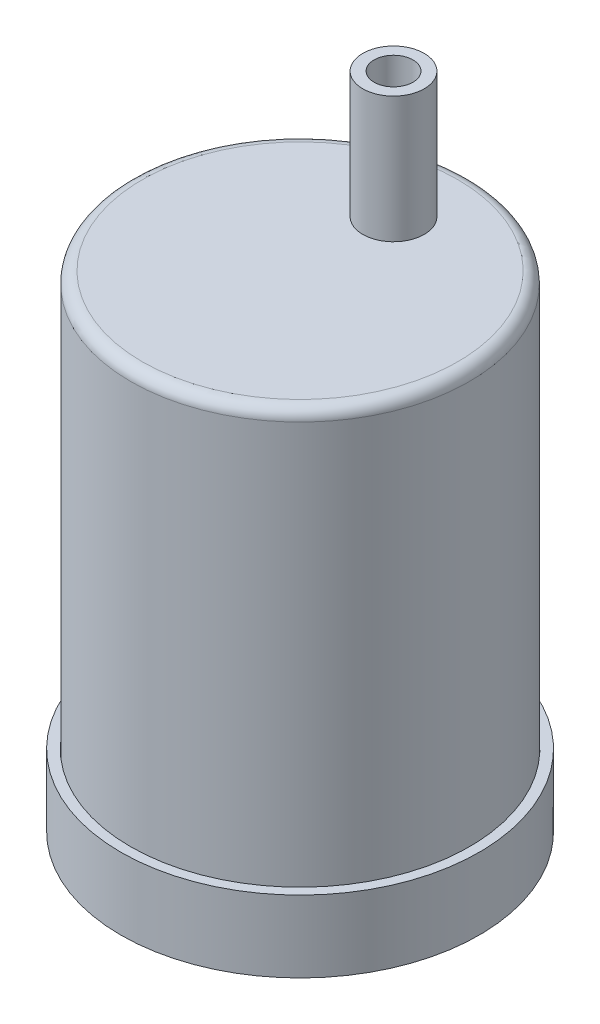
from build123d import *

# Parameters (mm, degrees)
SKETCH1_R            = 19.85
SKETCH1_R_2          = 18.78
BOSS_EXTRUDE3_DEPTH  = 7.95
SKETCH2_R            = 18.78
BOSS_EXTRUDE5_DEPTH  = 1.5
SKETCH4_R            = 12.5
BOSS_EXTRUDE6_DEPTH  = 16.31
SKETCH5_R            = 2.15
SKETCH5_W            = 4.3
SKETCH5_H            = 2.15
CUT_EXTRUDE2_DEPTH   = 16.31
SKETCH6_R            = 11.597360911
CUT_EXTRUDE3_DEPTH   = 14.809999892
SKETCH12_R           = 3.4
SKETCH12_W           = 6.8
SKETCH12_H           = 3.4
BOSS_EXTRUDE8_DEPTH  = 24.969999892
SKETCH5_6_R          = 2.15
SKETCH5_6_W          = 4.3
SKETCH5_6_H          = 2.15
CUT_EXTRUDE5_DEPTH   = 24.969999892
CUT_EXTRUDE6_START   = -14.81
SKETCH14_R           = 15.219310499
SKETCH14_R_2         = 12.5
CUT_EXTRUDE6_DEPTH   = 14.81
SKETCH17_W           = 6.8
SKETCH17_H           = 2.662223843
CUT_EXTRUDE7_DEPTH   = 16.587999892
SKETCH18_R           = 3.4
SKETCH18_R_2         = 2.15
BOSS_EXTRUDE10_DEPTH = 14
SKETCH19_R           = 5.618160511
SKETCH19_R_2         = 3.4
CUT_EXTRUDE8_DEPTH   = 14
SKETCH20_R           = 18.7419
SKETCH20_R_2         = 17.5419
BOSS_EXTRUDE11_DEPTH = 50.8
SKETCH21_R           = 18.7419
BOSS_EXTRUDE12_DEPTH = 1.5
SKETCH22_R           = 3.4
SKETCH22_R_2         = 2.15
BOSS_EXTRUDE13_DEPTH = 13.97
SKETCH23_R           = 2.15
CUT_EXTRUDE9_DEPTH   = 30.456
FILLET1_R            = 1.27
FILLET2_R            = 1.27


with BuildPart() as part:
    # Sketch1 → Boss-Extrude3 (new body)
    with BuildSketch(Plane(origin=(0, 0, 0), x_dir=(1, 0, 0), z_dir=(0, 1, 0))):
        Circle(SKETCH1_R)
        Circle(SKETCH1_R_2, mode=Mode.SUBTRACT)
    extrude(amount=BOSS_EXTRUDE3_DEPTH)

    # Sketch2 → Boss-Extrude5 (add)
    with BuildSketch(Plane.XZ):
        Circle(SKETCH2_R)
    extrude(amount=-BOSS_EXTRUDE5_DEPTH)


with BuildPart() as body_2:
    # Sketch4 → Boss-Extrude6 (new body)
    with BuildSketch(Plane.XZ):
        Circle(SKETCH4_R)
    extrude(amount=-BOSS_EXTRUDE6_DEPTH)


with BuildPart() as cut_extrude2_tool:
    # Sketch5 → Cut-Extrude2 (new body)
    with BuildSketch(Plane(origin=(0, 16.31, 0), x_dir=(1, 0, 0), z_dir=(0, 1, 0))):
        with Locations((0, 10.35)):
            Circle(SKETCH5_R)
        with Locations((0, 11.425)):
            Rectangle(SKETCH5_W, SKETCH5_H)
    extrude(amount=-CUT_EXTRUDE2_DEPTH)


with BuildPart() as part_1:
    add(part.part)

    # Cut-Extrude2: cut by cut_extrude2_tool
    add(cut_extrude2_tool.part, mode=Mode.SUBTRACT)


with BuildPart() as body_2_1:
    add(body_2.part)

    # Cut-Extrude2: cut by cut_extrude2_tool
    add(cut_extrude2_tool.part, mode=Mode.SUBTRACT)


with BuildPart() as cut_extrude3_tool:
    # Sketch6 → Cut-Extrude3 (new body)
    with BuildSketch(Plane.XZ):
        Circle(SKETCH6_R)
    extrude(amount=-CUT_EXTRUDE3_DEPTH)


with BuildPart() as part_2:
    add(part_1.part)

    # Cut-Extrude3: cut by cut_extrude3_tool
    add(cut_extrude3_tool.part, mode=Mode.SUBTRACT)



with BuildPart() as body_2_2:
    add(body_2_1.part)

    # Cut-Extrude3: cut by cut_extrude3_tool
    add(cut_extrude3_tool.part, mode=Mode.SUBTRACT)


with BuildPart() as part_3:
    add(part_2.part)

    add(body_2_2.part)  # Boss-Extrude8 merges body 2
    # Sketch12 → Boss-Extrude8 (add)
    with BuildSketch(Plane(origin=(0, 16.31, 0), x_dir=(1, 0, 0), z_dir=(0, 1, 0))):
        with Locations((0, 10.35)):
            Circle(SKETCH12_R)
        with Locations((0, 12.05)):
            Rectangle(SKETCH12_W, SKETCH12_H)
    extrude(amount=-BOSS_EXTRUDE8_DEPTH)

    # Sketch5_6 → Cut-Extrude5 (cut)
    with BuildSketch(Plane(origin=(0, 16.31, 0), x_dir=(1, 0, 0), z_dir=(0, 1, 0))):
        with Locations((0, 10.35)):
            Circle(SKETCH5_6_R)
        with Locations((0, 11.425)):
            Rectangle(SKETCH5_6_W, SKETCH5_6_H)
    extrude(amount=-CUT_EXTRUDE5_DEPTH, mode=Mode.SUBTRACT)

    # Sketch14 → Cut-Extrude6 (cut)
    with BuildSketch(Plane(origin=(0, 16.31, 0), x_dir=(1, 0, 0), z_dir=(0, 1, 0)).offset(CUT_EXTRUDE6_START)):
        Circle(SKETCH14_R)
        Circle(SKETCH14_R_2, mode=Mode.SUBTRACT)
    extrude(amount=CUT_EXTRUDE6_DEPTH, mode=Mode.SUBTRACT)

    # Sketch17 → Cut-Extrude7 (cut)
    with BuildSketch(Plane.XZ):
        with Locations((0, -12.418888079)):
            Rectangle(SKETCH17_W, SKETCH17_H)
    extrude(amount=CUT_EXTRUDE7_DEPTH, mode=Mode.SUBTRACT)

    # Sketch18 → Boss-Extrude10 (add)
    with BuildSketch(Plane.XZ):
        with Locations((0, -10.35)):
            Circle(SKETCH18_R)
        with Locations((0, -10.35)):
            Circle(SKETCH18_R_2, mode=Mode.SUBTRACT)
    extrude(amount=BOSS_EXTRUDE10_DEPTH)

    # Sketch19 → Cut-Extrude8 (cut)
    with BuildSketch(Plane.XZ):
        with Locations((0, -10.35)):
            Circle(SKETCH19_R)
        with Locations((0, -10.35)):
            Circle(SKETCH19_R_2, mode=Mode.SUBTRACT)
    extrude(amount=CUT_EXTRUDE8_DEPTH, mode=Mode.SUBTRACT)


with BuildPart() as body_2_2_1:
    # Sketch20 → Boss-Extrude11 (new body)
    with BuildSketch(Plane(origin=(0, 1.5, 0), x_dir=(1, 0, 0), z_dir=(0, 1, 0))):
        Circle(SKETCH20_R)
        Circle(SKETCH20_R_2, mode=Mode.SUBTRACT)
    extrude(amount=BOSS_EXTRUDE11_DEPTH)

    # Sketch21 → Boss-Extrude12 (add)
    with BuildSketch(Plane(origin=(0, 52.3, 0), x_dir=(1, 0, 0), z_dir=(0, 1, 0))):
        Circle(SKETCH21_R)
    extrude(amount=BOSS_EXTRUDE12_DEPTH)

    # Sketch22 → Boss-Extrude13 (add)
    with BuildSketch(Plane(origin=(0, 53.8, 0), x_dir=(1, 0, 0), z_dir=(0, 1, 0))):
        with Locations((0, 10.35)):
            Circle(SKETCH22_R)
        with Locations((0, 10.35)):
            Circle(SKETCH22_R_2, mode=Mode.SUBTRACT)
    extrude(amount=BOSS_EXTRUDE13_DEPTH)

    # Sketch23 → Cut-Extrude9 (cut)
    with BuildSketch(Plane(origin=(0, 67.77, 0), x_dir=(1, 0, 0), z_dir=(0, 1, 0))):
        with Locations((0, 10.35)):
            Circle(SKETCH23_R)
    extrude(amount=-CUT_EXTRUDE9_DEPTH, mode=Mode.SUBTRACT)

    # Fillet1
    fillet1_edges = [body_2_2_1.edges().sort_by_distance(p)[0] for p in [
        (-17.5419, 52.3, 0),
    ]]
    fillet(fillet1_edges, radius=FILLET1_R)

    # Fillet2
    fillet2_edges = [body_2_2_1.edges().sort_by_distance(p)[0] for p in [
        (-18.7419, 53.8, 0),
    ]]
    fillet(fillet2_edges, radius=FILLET2_R)


solid = Compound([part_3.part, body_2_2_1.part])
